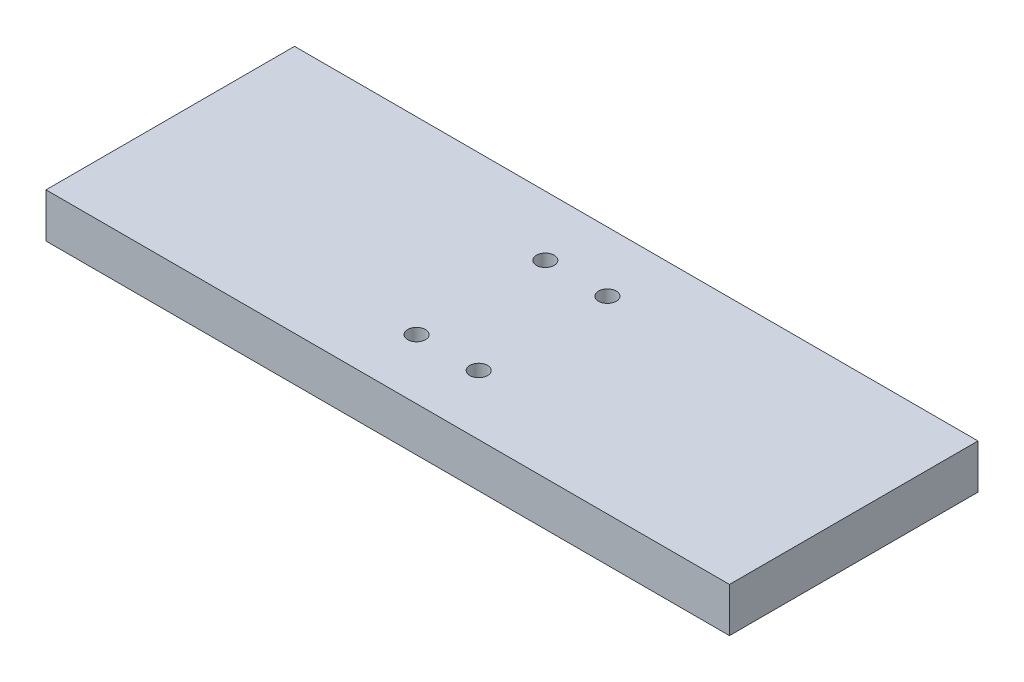
from build123d import *

# Parameters (mm, degrees)
SKETCH1_W                 = 154
SKETCH1_H                 = 56
BOSS_EXTRUDE1_DEPTH       = 10
F_4_0MM_DOWEL_HOLE3_D     = 4
F_4_0MM_DOWEL_HOLE3_DEPTH = 7
F_4_0MM_DOWEL_HOLE3_TIP   = 1.201721238


with BuildPart() as part:
    # Sketch1 → Boss-Extrude1 (new body)
    with BuildSketch(Plane(origin=(0, 0, 0), x_dir=(1, 0, 0), z_dir=(0, 1, 0))):
        Rectangle(SKETCH1_W, SKETCH1_H)
    extrude(amount=BOSS_EXTRUDE1_DEPTH)

    # Ø4.0mm Dowel Hole3
    with Locations(Plane(origin=(-7, 10, -14.5), x_dir=(0, 0, 1), z_dir=(0, 1, 0))):
        with Locations((0, 0), (29, 0), (29, 14), (0, 14)):
            Hole(F_4_0MM_DOWEL_HOLE3_D / 2, depth=F_4_0MM_DOWEL_HOLE3_DEPTH)
            with Locations((0, 0, -(F_4_0MM_DOWEL_HOLE3_DEPTH + F_4_0MM_DOWEL_HOLE3_TIP / 2))):  # 118° drill point
                Cone(0, F_4_0MM_DOWEL_HOLE3_D / 2, F_4_0MM_DOWEL_HOLE3_TIP, mode=Mode.SUBTRACT)


solid = part.part
